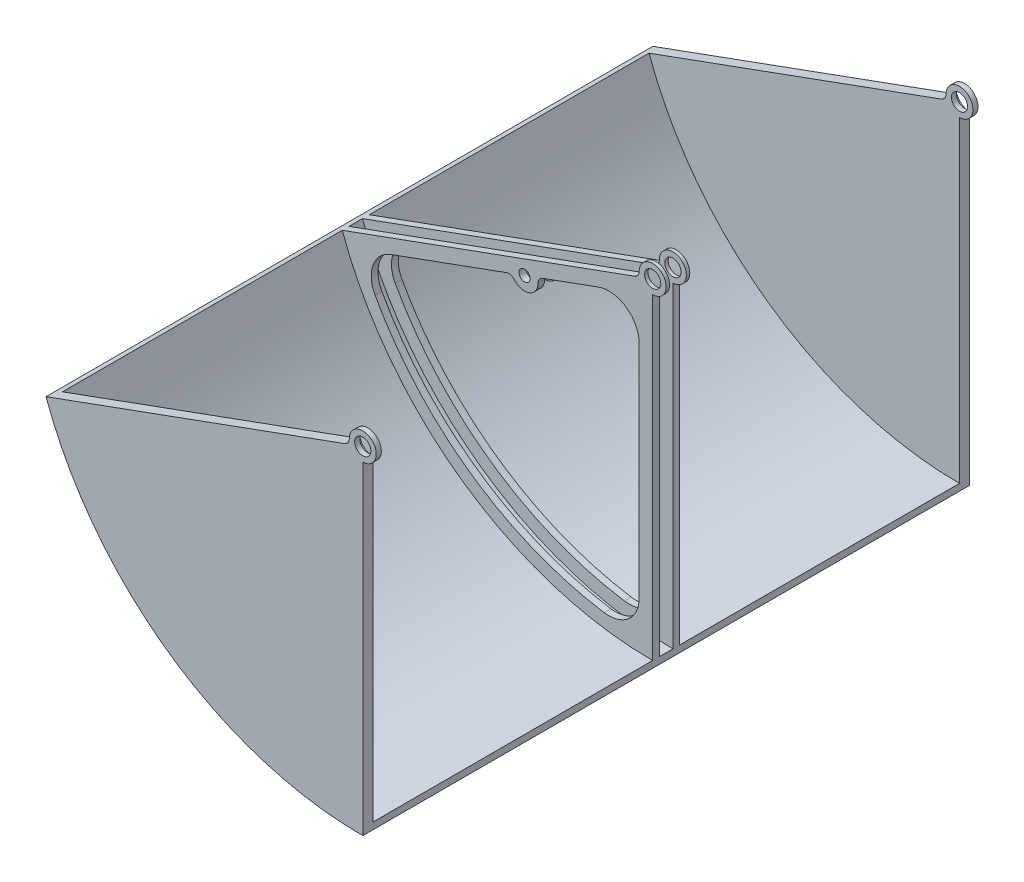
from build123d import *

# Parameters (mm, degrees)
DODANIE_WYCI_GNI_CIE1_DEPTH = 900
SKORUPA1_T                  = -10
SZKIC4_R                    = 12
DODANIE_WYCI_GNI_CIE3_DEPTH = 15
SZKIC6_R                    = 12
SZKIC6_R_2                  = 8.15
DODANIE_WYCI_GNI_CIE4_DEPTH = 10
ZAOKR_GLENIE3_R             = 45
SZKIC8_R                    = 20
WYTNIJ_WYCI_GNI_CIE1_DEPTH  = 7.5
SZKIC11_R                   = 20
WYTNIJ_WYCI_GNI_CIE2_DEPTH  = 5
SZKIC12_R                   = 20
WYTNIJ_WYCI_GNI_CIE3_DEPTH  = 5
SZKIC13_R                   = 20
WYTNIJ_WYCI_GNI_CIE4_DEPTH  = 7.5
ZAOKR_GLENIE4_R             = 10
ZAOKR_GLENIE5_R             = 10


with BuildPart() as part:
    # Szkic1 → Dodanie-wyciągnięcie1 (new body)
    with BuildSketch(Plane.XY):
        with BuildLine():
            Line((-469.846310393, -171.010071663), (0, 0))
            Line((0, 0), (0, -500))
            ThreePointArc((0, -500), (-286.788218176, -409.576022144), (-469.846310393, -171.010071663))
        make_face()
    extrude(amount=DODANIE_WYCI_GNI_CIE1_DEPTH)

    # Skorupa1
    skorupa1_openings = [part.faces().sort_by_distance(p)[0] for p in [
        (-179.521279962, -256.382958146, 900),
        (-179.521279962, -256.382958146, 0),
        (-234.923155196, -85.505035831, 450),
        (0, -250, 450),
    ]]
    offset(amount=SKORUPA1_T, openings=skorupa1_openings, kind=Kind.INTERSECTION)

    # Szkic4 → Dodanie-wyciągnięcie3 (add)
    with BuildSketch(Plane(origin=(0, 0, 0), x_dir=(-1, 0, 0), z_dir=(0, 0, -1))):
        with BuildLine():
            Line((0, -20), (0, -490))
            ThreePointArc((0, -490), (281.052453812, -401.384501702), (460.449384185, -167.58987023))
            Line((460.449384185, -167.58987023), (18.793852416, -6.840402867))
            ThreePointArc((18.793852416, -6.840402867), (-11.471528727, 16.383040886), (0, -20))
        make_face()
        Circle(SZKIC4_R, mode=Mode.SUBTRACT)
    dodanie_wyci_gni_cie3 = extrude(amount=-DODANIE_WYCI_GNI_CIE3_DEPTH)

    # Lustro1: Dodanie-wyciągnięcie3 across plane
    add(dodanie_wyci_gni_cie3.mirror(Plane.XY.offset(450)))

    # Szkic6 → Dodanie-wyciągnięcie4 (add)
    with BuildSketch(Plane.XY.offset(440)):
        with BuildLine():
            Line((-18.793852416, -6.840402867), (-460.449384185, -167.58987023))
            ThreePointArc((-460.449384185, -167.58987023), (-281.052453812, -401.384501702), (0, -490))
            Line((0, -490), (0, -20))
            ThreePointArc((0, -20), (11.471528727, 16.383040886), (-18.793852416, -6.840402867))
        make_face()
        with Locations(Location((0, 0, 0), (0, 0, 180))):
            Circle(SZKIC6_R, mode=Mode.SUBTRACT)
        with Locations((-190.094997116, -90.472476083)):
            Circle(SZKIC6_R_2, mode=Mode.SUBTRACT)
        with BuildLine():
            Line((-20, -28.562960135), (-20, -469.574275275))
            ThreePointArc((-20, -469.574275275), (-269.580925085, -385.001460816), (-434.41507852, -179.397713347))
            Line((-434.41507852, -179.397713347), (-208.888849532, -97.312878949))
            ThreePointArc((-208.888849532, -97.312878949), (-183.254594249, -109.266328498), (-171.3011447, -83.632073216))
            Line((-171.3011447, -83.632073216), (-20, -28.562960135))
        make_face(mode=Mode.SUBTRACT)
    dodanie_wyci_gni_cie4 = extrude(amount=-DODANIE_WYCI_GNI_CIE4_DEPTH)

    # Lustro6: Dodanie-wyciągnięcie4 across plane
    add(dodanie_wyci_gni_cie4.mirror(Plane.XY.offset(450)))

    # Zaokrąglenie3
    zaokr_glenie3_edges = [part.edges().sort_by_distance(p)[0] for p in [
        (-434.41507852, -179.397713347, 435),
        (-20, -28.562960135, 435),
        (-20, -469.574275275, 435),
        (-20, -469.574275275, 465),
        (-20, -28.562960135, 465),
        (-434.41507852, -179.397713347, 465),
    ]]
    fillet(zaokr_glenie3_edges, radius=ZAOKR_GLENIE3_R)

    # Szkic8 → Wytnij-wyciągnięcie1 (cut)
    with BuildSketch(Plane(origin=(0, 0, 0), x_dir=(-1, 0, 0), z_dir=(0, 0, -1))):
        Circle(SZKIC8_R)
    extrude(amount=-WYTNIJ_WYCI_GNI_CIE1_DEPTH, mode=Mode.SUBTRACT)

    # Szkic11 → Wytnij-wyciągnięcie2 (cut)
    with BuildSketch(Plane(origin=(0, 0, 430), x_dir=(-1, 0, 0), z_dir=(0, 0, -1))):
        Circle(SZKIC11_R)
    extrude(amount=-WYTNIJ_WYCI_GNI_CIE2_DEPTH, mode=Mode.SUBTRACT)

    # Szkic12 → Wytnij-wyciągnięcie3 (cut)
    with BuildSketch(Plane(origin=(0, 0, 460), x_dir=(-1, 0, 0), z_dir=(0, 0, -1))):
        Circle(SZKIC12_R)
    extrude(amount=-WYTNIJ_WYCI_GNI_CIE3_DEPTH, mode=Mode.SUBTRACT)

    # Szkic13 → Wytnij-wyciągnięcie4 (cut)
    with BuildSketch(Plane(origin=(0, 0, 885), x_dir=(-1, 0, 0), z_dir=(0, 0, -1))):
        Circle(SZKIC13_R)
    extrude(amount=-WYTNIJ_WYCI_GNI_CIE4_DEPTH, mode=Mode.SUBTRACT)

    # Zaokrąglenie4
    zaokr_glenie4_edges = [part.edges().sort_by_distance(p)[0] for p in [
        (-18.793852416, -6.840402867, 437.5),
        (-18.793852416, -6.840402867, 896.25),
        (-18.793852416, -6.840402867, 11.25),
        (-18.793852416, -6.840402867, 467.5),
    ]]
    fillet(zaokr_glenie4_edges, radius=ZAOKR_GLENIE4_R)

    # Zaokrąglenie5
    zaokr_glenie5_edges = [part.edges().sort_by_distance(p)[0] for p in [
        (-208.888849532, -97.312878949, 435),
        (-171.3011447, -83.632073216, 435),
        (-171.3011447, -83.632073216, 465),
        (-208.888849532, -97.312878949, 465),
    ]]
    fillet(zaokr_glenie5_edges, radius=ZAOKR_GLENIE5_R)


solid = part.part
